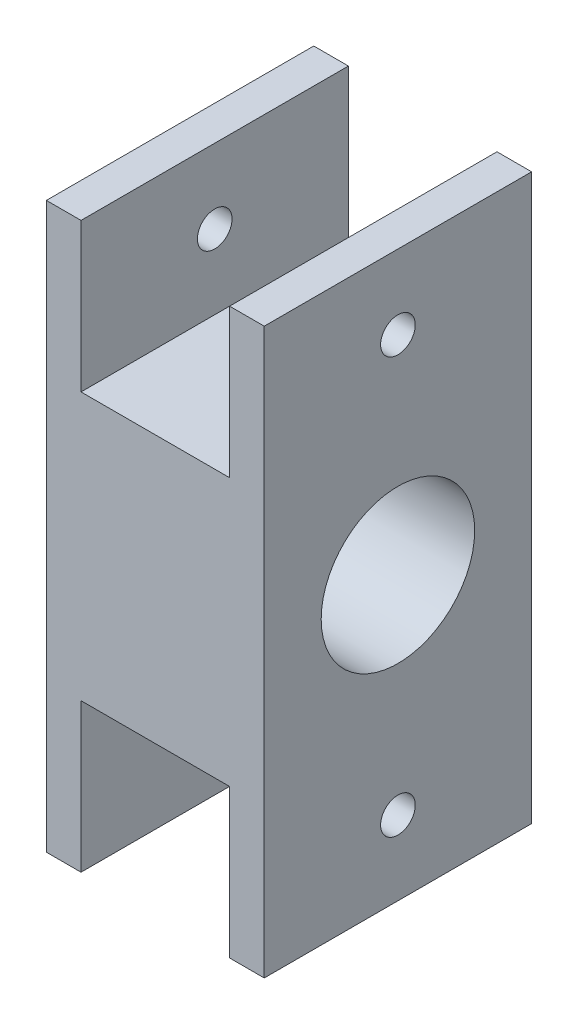
from build123d import *

# Parameters (mm, degrees)
BOSS_EXTRUDE1_DEPTH = 53.99999995
HOLE1_D             = 6.99999997
HOLE2_D             = 30.999999976
HOLE2_CBORE_D       = 40.00000001
HOLE2_CBORE_DEPTH   = 11.999999876


with BuildPart() as part:
    # Sketch1 → Boss-Extrude1 (new body)
    with BuildSketch(Plane.XY):
        Polygon((-21.999999942, 56.999999919), (-14.999999972, 56.999999919), (-14.999999972, 26.999999975), (14.999999972, 26.999999975), (14.999999972, 56.999999919), (21.999999942, 56.999999919), (21.999999942, -56.999999919), (14.999999972, -56.999999919), (14.999999972, -26.999999975), (-14.999999972, -26.999999975), (-14.999999972, -56.999999919), (-21.999999942, -56.999999919), align=None)
    extrude(amount=BOSS_EXTRUDE1_DEPTH)

    # Hole1 (through all)
    with Locations(Plane.ZY.offset(21.999999942)):
        with Locations((26.999999975, 41.999999947), (26.999999975, -41.999999947)):
            Hole(HOLE1_D / 2)

    # Hole2 (through all)
    with Locations(Plane.ZY.offset(21.999999942)):
        with Locations((26.999999975, 0)):
            CounterBoreHole(HOLE2_D / 2, HOLE2_CBORE_D / 2, HOLE2_CBORE_DEPTH)


solid = part.part
